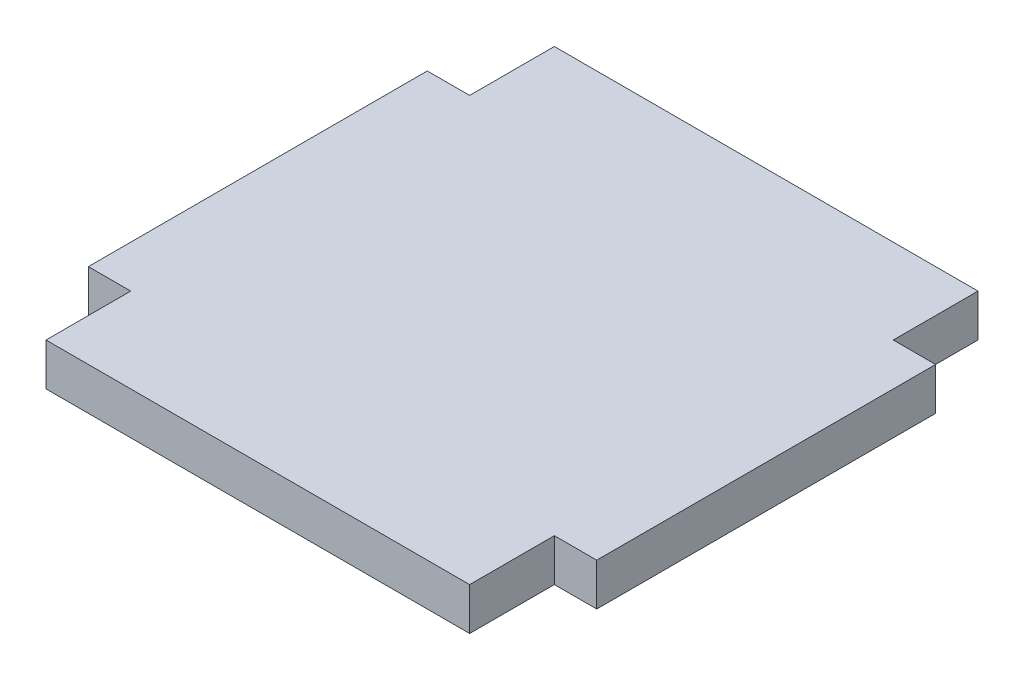
from build123d import *

# Parameters (mm, degrees)
SKETCH1_W           = 38.1
SKETCH1_H           = 38.1
BOSS_EXTRUDE1_DEPTH = 3.175
SKETCH2_W           = 3.175
SKETCH2_H           = 6.35
CUT_EXTRUDE1_DEPTH  = 3.175


with BuildPart() as part:
    # Sketch1 → Boss-Extrude1 (new body)
    with BuildSketch(Plane(origin=(0, 0, 0), x_dir=(1, 0, 0), z_dir=(0, 1, 0))):
        with Locations((19.05, 19.05)):
            Rectangle(SKETCH1_W, SKETCH1_H)
    extrude(amount=BOSS_EXTRUDE1_DEPTH)

    # Sketch2 → Cut-Extrude1 (cut)
    with BuildSketch(Plane.XZ):
        with Locations((36.5125, -34.925)):
            Rectangle(SKETCH2_W, SKETCH2_H)
        with Locations((36.5125, -3.175)):
            Rectangle(SKETCH2_W, SKETCH2_H)
        with Locations((1.5875, -34.925)):
            Rectangle(SKETCH2_W, SKETCH2_H)
        with Locations((1.5875, -3.175)):
            Rectangle(SKETCH2_W, SKETCH2_H)
    extrude(amount=-CUT_EXTRUDE1_DEPTH, mode=Mode.SUBTRACT)


solid = part.part
